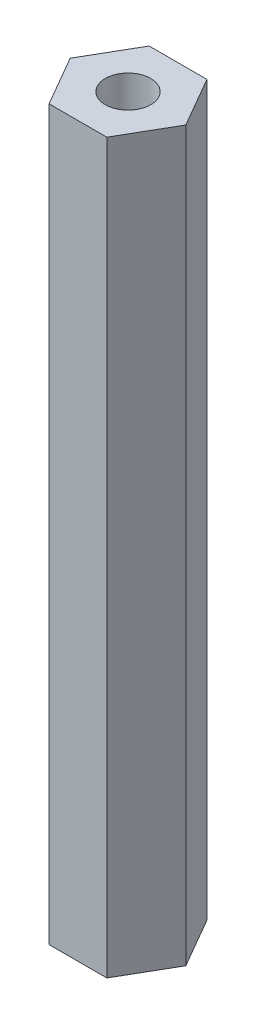
from build123d import *

# Parameters (mm, degrees)
BOSS_EXTRUDE1_DEPTH = 20
M3_TAPPED_HOLE1_D   = 2.5


with BuildPart() as part:
    # Sketch1 → Boss-Extrude1 (new body, symmetric)
    with BuildSketch(Plane(origin=(0, 0, 0), x_dir=(1, 0, 0), z_dir=(0, 1, 0))):
        Polygon((3.175426481, 0), (1.58771324, 2.75), (-1.58771324, 2.75), (-3.175426481, 0), (-1.58771324, -2.75), (1.58771324, -2.75), align=None)
    extrude(amount=BOSS_EXTRUDE1_DEPTH, both=True)

    # M3 Tapped Hole1 (through all)
    with Locations(Plane(origin=(0, 20, 0), x_dir=(1, 0, 0), z_dir=(0, 1, 0))):
        with Locations((0, 0)):
            Hole(M3_TAPPED_HOLE1_D / 2)


solid = part.part
